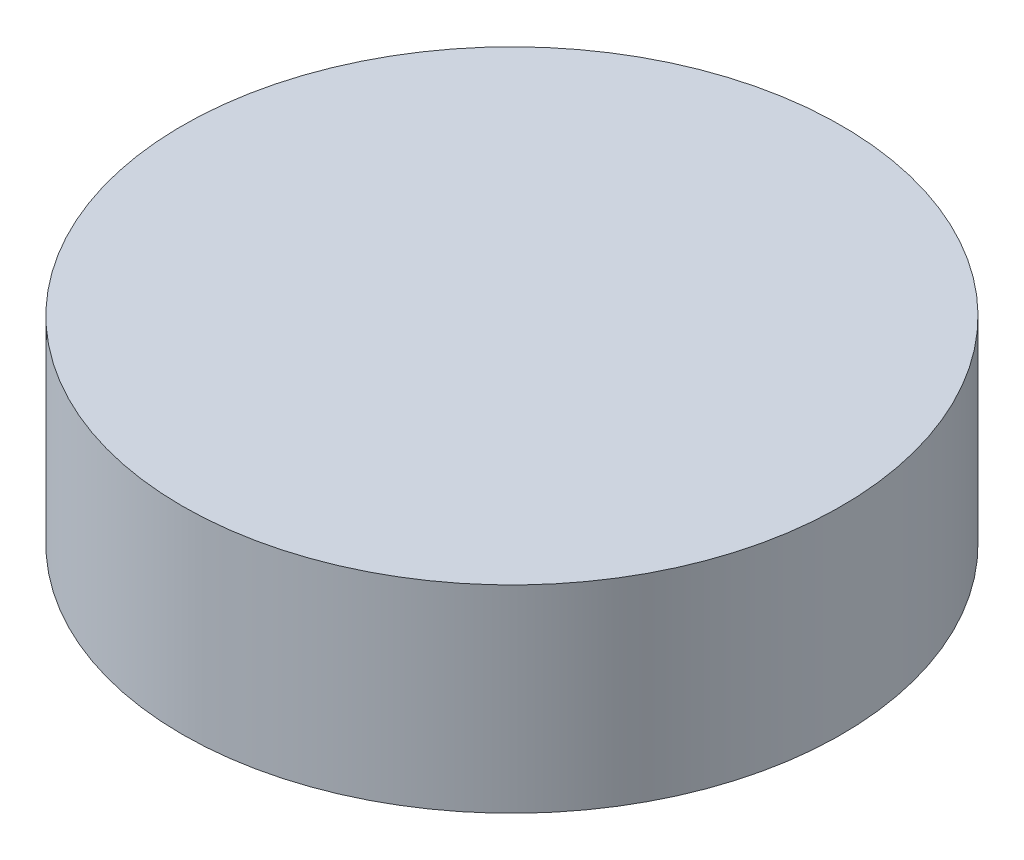
from build123d import *

# Parameters (mm, degrees)
ESQUISSE1_R        = 40
BOSS_EXTRU_1_DEPTH = 24


with BuildPart() as part:
    # Esquisse1 → Boss.-Extru.1 (new body)
    with BuildSketch(Plane(origin=(0, 0, 0), x_dir=(1, 0, 0), z_dir=(0, 1, 0))):
        Circle(ESQUISSE1_R)
    extrude(amount=BOSS_EXTRU_1_DEPTH)


solid = part.part
